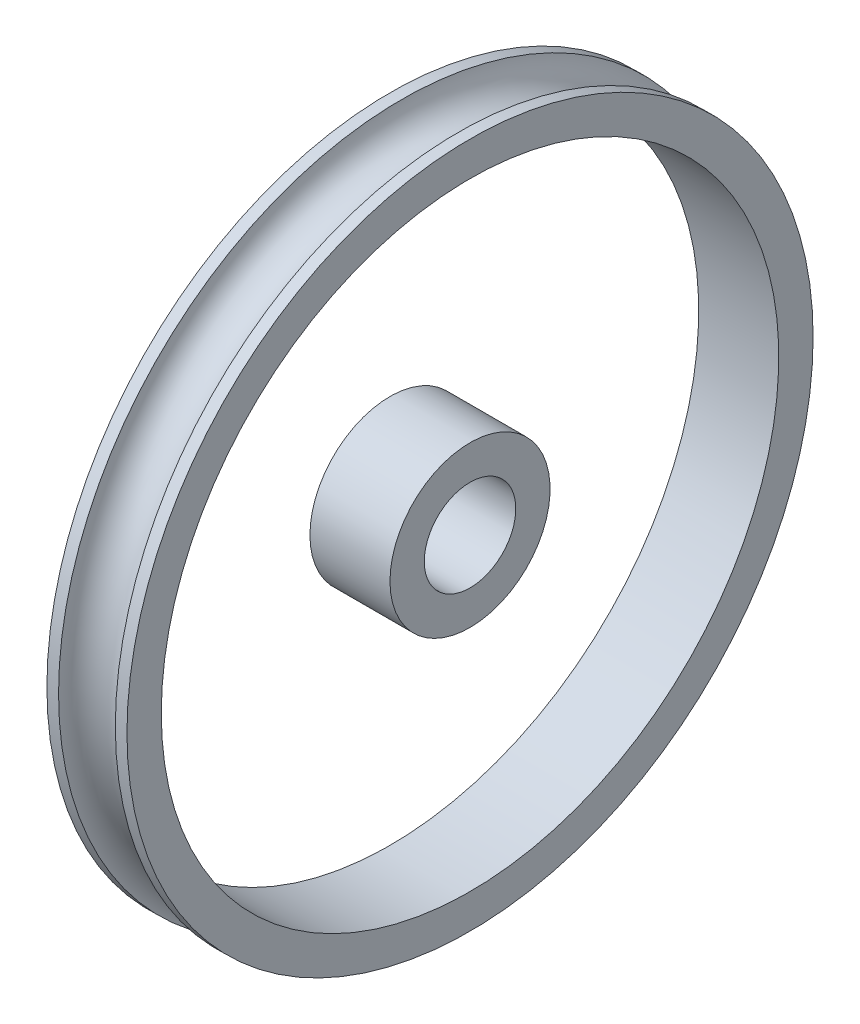
from build123d import *

# Parameters (mm, degrees)
SKETCH1_W = 7
SKETCH1_H = 3


with BuildPart() as part:
    # Sketch1 → Revolve1 (revolve)
    with BuildSketch(Plane(origin=(0, 0, 0), x_dir=(1, 0, 0), z_dir=(0, 1, 0))):
        with Locations((3.5, 5.5)):
            Rectangle(SKETCH1_W, SKETCH1_H)
        with BuildLine():
            Line((0, 30), (1.018065271, 30))
            ThreePointArc((1.018065271, 30), (3.5, 27.8), (5.981934729, 30))
            Line((5.981934729, 30), (7, 30))
            Line((7, 30), (7, 27))
            Line((7, 27), (0, 27))
            Line((0, 27), (0, 30))
        make_face()
    revolve(axis=Axis((0, 0, 0), (1, 0, 0)))


solid = part.part
